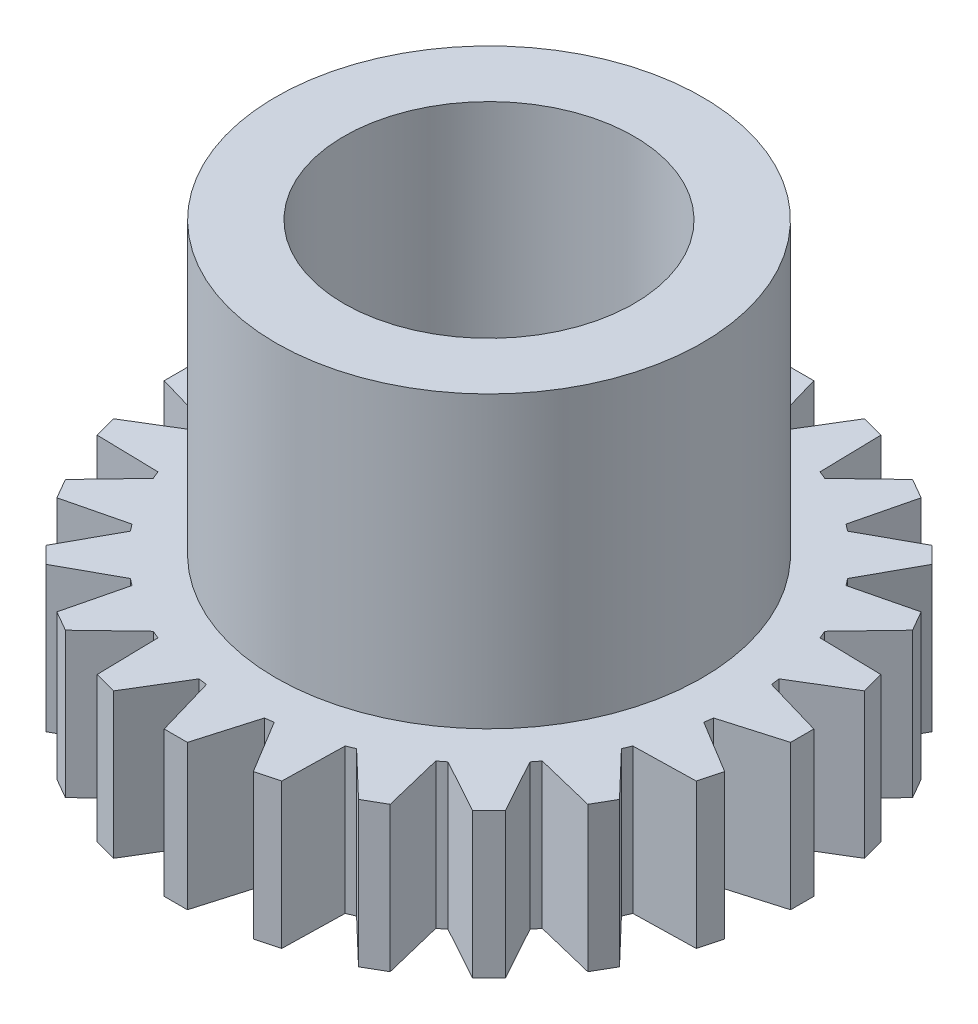
from build123d import *

# Parameters (mm, degrees)
SKETCH1_R           = 4.66725
SKETCH1_R_2         = 3.175
BOSS_EXTRUDE1_DEPTH = 9.525
BOSS_EXTRUDE2_DEPTH = 3.175
BOSS_EXTRUDE3_DEPTH = 3.175
CIRPATTERN1_COUNT   = 24


with BuildPart() as part:
    # Sketch1 → Boss-Extrude1 (new body)
    with BuildSketch(Plane(origin=(0, 0, 0), x_dir=(1, 0, 0), z_dir=(0, 1, 0))):
        Circle(SKETCH1_R)
        Circle(SKETCH1_R_2, mode=Mode.SUBTRACT)
    extrude(amount=BOSS_EXTRUDE1_DEPTH)

    # Sketch2 → Boss-Extrude2 (add)
    with BuildSketch(Plane(origin=(0, 0, 0), x_dir=(1, 0, 0), z_dir=(0, 1, 0))):
        with BuildLine():
            Line((0.635, 5.551803221), (-0.635, 5.551803221))
            ThreePointArc((-0.635, 5.551803221), (-3.720037903, -4.16977961), (5.588, 0))
            ThreePointArc((5.588, 0), (4.16977961, 3.720037903), (0.635, 5.551803221))
        make_face()
    extrude(amount=BOSS_EXTRUDE2_DEPTH)

    # Sketch2_3 → Boss-Extrude3 (add)
    with BuildSketch(Plane(origin=(0, 0, 0), x_dir=(1, 0, 0), z_dir=(0, 1, 0))):
        Polygon((-0.635, 5.551803221), (0.635, 5.551803221), (0.254, 6.858), (-0.254, 6.858), align=None)
    boss_extrude3 = extrude(amount=BOSS_EXTRUDE3_DEPTH)

    # CirPattern1: Boss-Extrude3 ×24 about axis
    cirpattern1_axis = Axis((0, 9.525, 0), (0, -1, 0))
    for i in range(1, CIRPATTERN1_COUNT):
        add(boss_extrude3.rotate(cirpattern1_axis, i * 360 / CIRPATTERN1_COUNT))


solid = part.part
